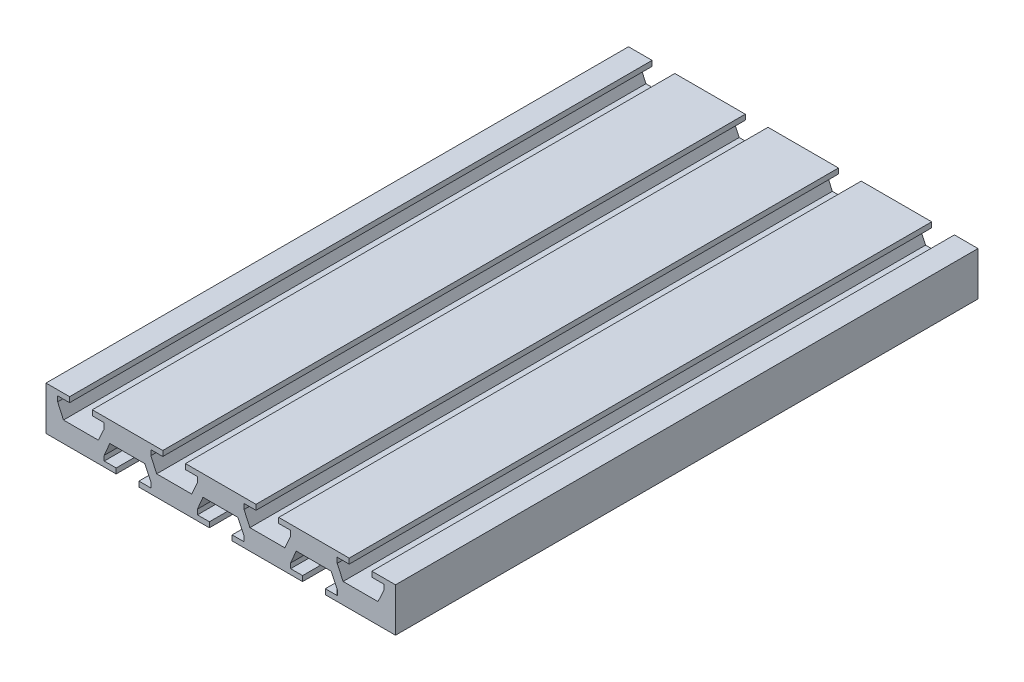
from build123d import *

# Parameters (mm, degrees)
BOSS_EXTRUDE1_DEPTH = 200


with BuildPart() as part:
    # Sketch1 → Boss-Extrude1 (new body)
    with BuildSketch(Plane.XY):
        Polygon((60, -7.5), (35.9, -7.5), (35.9, -5.7), (40, -5.7), (40, -3.9), (37.900227313, 0.5), (25.900227313, 0.5), (24, -3.989786353), (24, -5.7), (28.1, -5.7), (28.1, -7.5), (3.9, -7.5), (3.9, -5.7), (8, -5.7), (8, -3.9), (5.900227313, 0.5), (-6.099772687, 0.5), (-8, -3.989786353), (-8, -5.7), (-3.9, -5.7), (-3.9, -7.5), (-28.1, -7.5), (-28.1, -5.7), (-24, -5.7), (-24, -3.9), (-26.099772687, 0.5), (-38.099772687, 0.5), (-40, -3.989786353), (-40, -5.7), (-35.9, -5.7), (-35.9, -7.5), (-60, -7.5), (-60, 7.5), (-51.9, 7.5), (-51.9, 5.7), (-56, 5.7), (-56, 3.9), (-54, -0.5), (-42, -0.5), (-40, 3.9), (-40, 5.7), (-44.1, 5.7), (-44.1, 7.5), (-19.9, 7.5), (-19.9, 5.7), (-24, 5.7), (-24, 3.9), (-22, -0.5), (-10, -0.5), (-8, 3.9), (-8, 5.7), (-12.1, 5.7), (-12.1, 7.5), (12.1, 7.5), (12.1, 5.7), (8, 5.7), (8, 3.9), (10, -0.5), (22, -0.5), (24, 3.9), (24, 5.7), (19.9, 5.7), (19.9, 7.5), (44.1, 7.5), (44.1, 5.7), (40, 5.7), (40, 3.9), (42, -0.5), (54, -0.5), (56, 3.9), (56, 5.7), (51.9, 5.7), (51.9, 7.5), (60, 7.5), align=None)
    extrude(amount=BOSS_EXTRUDE1_DEPTH)


solid = part.part
